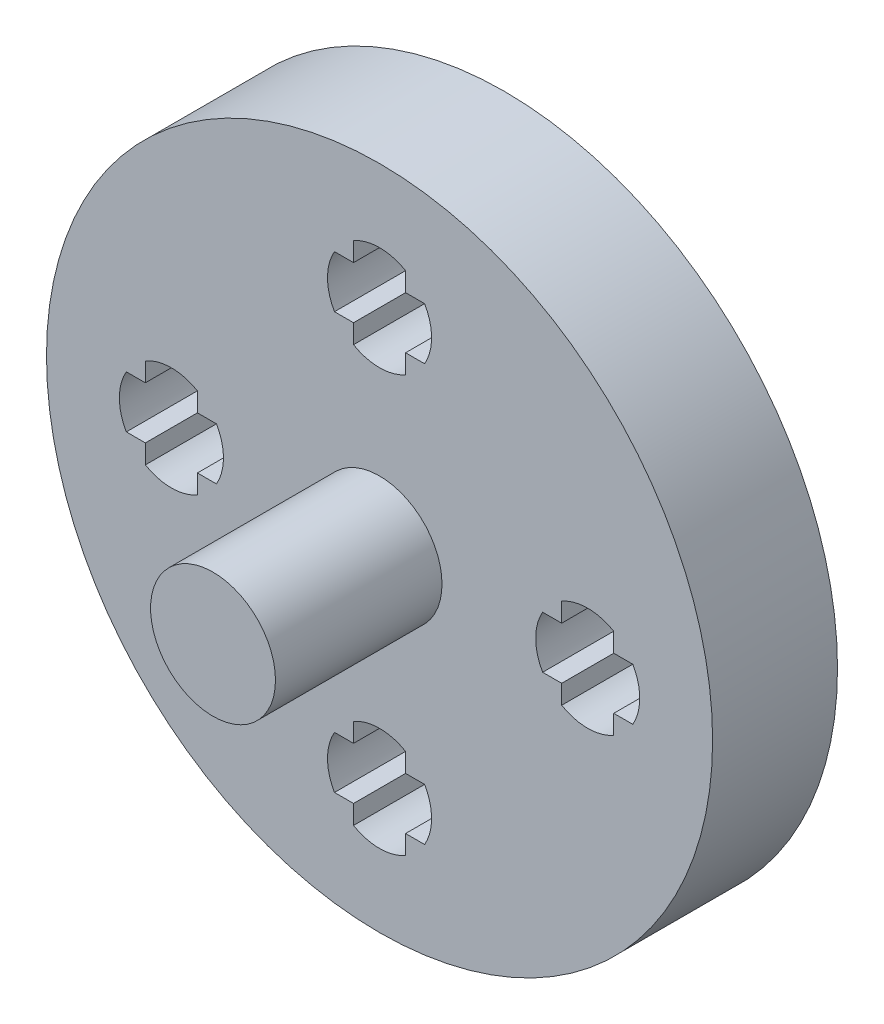
from build123d import *

# Parameters (mm, degrees)
CROQUIS1_R              = 16
SALIENTE_EXTRUIR1_DEPTH = 6
CROQUIS2_R              = 3
SALIENTE_EXTRUIR2_DEPTH = 8


with BuildPart() as part:
    # Croquis1 → Saliente-Extruir1 (new body)
    with BuildSketch(Plane.XY):
        Circle(CROQUIS1_R)
        with BuildLine():
            Line((2.165063509, 11.25), (1.25, 11.25))
            Line((1.25, 11.25), (1.25, 12.165063509))
            ThreePointArc((1.25, 12.165063509), (0.647047613, 12.414814566), (0, 12.5))
            ThreePointArc((0, 12.5), (-0.647047613, 12.414814566), (-1.25, 12.165063509))
            Line((-1.25, 12.165063509), (-1.25, 11.25))
            Line((-1.25, 11.25), (-2.165063509, 11.25))
            ThreePointArc((-2.165063509, 11.25), (-2.414814566, 10.647047613), (-2.5, 10))
            ThreePointArc((-2.5, 10), (-2.414814566, 9.352952387), (-2.165063509, 8.75))
            Line((-2.165063509, 8.75), (-1.25, 8.75))
            Line((-1.25, 8.75), (-1.25, 7.834936491))
            ThreePointArc((-1.25, 7.834936491), (-0.647047613, 7.585185434), (0, 7.5))
            ThreePointArc((0, 7.5), (0.647047613, 7.585185434), (1.25, 7.834936491))
            Line((1.25, 7.834936491), (1.25, 8.75))
            Line((1.25, 8.75), (2.165063509, 8.75))
            ThreePointArc((2.165063509, 8.75), (2.414814566, 9.352952387), (2.5, 10))
            ThreePointArc((2.5, 10), (2.414814566, 10.647047613), (2.165063509, 11.25))
        make_face(mode=Mode.SUBTRACT)
        with BuildLine():
            Line((11.25, -1.25), (12.165063509, -1.25))
            ThreePointArc((12.165063509, -1.25), (12.414814566, -0.647047613), (12.5, 0))
            ThreePointArc((12.5, 0), (12.414814566, 0.647047613), (12.165063509, 1.25))
            Line((12.165063509, 1.25), (11.25, 1.25))
            Line((11.25, 1.25), (11.25, 2.165063509))
            ThreePointArc((11.25, 2.165063509), (10.647047613, 2.414814566), (10, 2.5))
            ThreePointArc((10, 2.5), (9.352952387, 2.414814566), (8.75, 2.165063509))
            Line((8.75, 2.165063509), (8.75, 1.25))
            Line((8.75, 1.25), (7.834936491, 1.25))
            ThreePointArc((7.834936491, 1.25), (7.585185434, 0.647047613), (7.5, 0))
            ThreePointArc((7.5, 0), (7.585185434, -0.647047613), (7.834936491, -1.25))
            Line((7.834936491, -1.25), (8.75, -1.25))
            Line((8.75, -1.25), (8.75, -2.165063509))
            ThreePointArc((8.75, -2.165063509), (9.352952387, -2.414814566), (10, -2.5))
            ThreePointArc((10, -2.5), (10.647047613, -2.414814566), (11.25, -2.165063509))
            Line((11.25, -2.165063509), (11.25, -1.25))
        make_face(mode=Mode.SUBTRACT)
        with BuildLine():
            Line((-1.25, -11.25), (-1.25, -12.165063509))
            ThreePointArc((-1.25, -12.165063509), (-0.647047613, -12.414814566), (0, -12.5))
            ThreePointArc((0, -12.5), (0.647047613, -12.414814566), (1.25, -12.165063509))
            Line((1.25, -12.165063509), (1.25, -11.25))
            Line((1.25, -11.25), (2.165063509, -11.25))
            ThreePointArc((2.165063509, -11.25), (2.414814566, -10.647047613), (2.5, -10))
            ThreePointArc((2.5, -10), (2.414814566, -9.352952387), (2.165063509, -8.75))
            Line((2.165063509, -8.75), (1.25, -8.75))
            Line((1.25, -8.75), (1.25, -7.834936491))
            ThreePointArc((1.25, -7.834936491), (0.647047613, -7.585185434), (0, -7.5))
            ThreePointArc((0, -7.5), (-0.647047613, -7.585185434), (-1.25, -7.834936491))
            Line((-1.25, -7.834936491), (-1.25, -8.75))
            Line((-1.25, -8.75), (-2.165063509, -8.75))
            ThreePointArc((-2.165063509, -8.75), (-2.414814566, -9.352952387), (-2.5, -10))
            ThreePointArc((-2.5, -10), (-2.414814566, -10.647047613), (-2.165063509, -11.25))
            Line((-2.165063509, -11.25), (-1.25, -11.25))
        make_face(mode=Mode.SUBTRACT)
        with BuildLine():
            Line((-11.25, 1.25), (-12.165063509, 1.25))
            ThreePointArc((-12.165063509, 1.25), (-12.414814566, 0.647047613), (-12.5, 0))
            ThreePointArc((-12.5, 0), (-12.414814566, -0.647047613), (-12.165063509, -1.25))
            Line((-12.165063509, -1.25), (-11.25, -1.25))
            Line((-11.25, -1.25), (-11.25, -2.165063509))
            ThreePointArc((-11.25, -2.165063509), (-10.647047613, -2.414814566), (-10, -2.5))
            ThreePointArc((-10, -2.5), (-9.352952387, -2.414814566), (-8.75, -2.165063509))
            Line((-8.75, -2.165063509), (-8.75, -1.25))
            Line((-8.75, -1.25), (-7.834936491, -1.25))
            ThreePointArc((-7.834936491, -1.25), (-7.585185434, -0.647047613), (-7.5, 0))
            ThreePointArc((-7.5, 0), (-7.585185434, 0.647047613), (-7.834936491, 1.25))
            Line((-7.834936491, 1.25), (-8.75, 1.25))
            Line((-8.75, 1.25), (-8.75, 2.165063509))
            ThreePointArc((-8.75, 2.165063509), (-9.352952387, 2.414814566), (-10, 2.5))
            ThreePointArc((-10, 2.5), (-10.647047613, 2.414814566), (-11.25, 2.165063509))
            Line((-11.25, 2.165063509), (-11.25, 1.25))
        make_face(mode=Mode.SUBTRACT)
    extrude(amount=SALIENTE_EXTRUIR1_DEPTH)

    # Croquis2 → Saliente-Extruir2 (add)
    with BuildSketch(Plane.XY.offset(6)):
        Circle(CROQUIS2_R)
    extrude(amount=SALIENTE_EXTRUIR2_DEPTH)


solid = part.part
